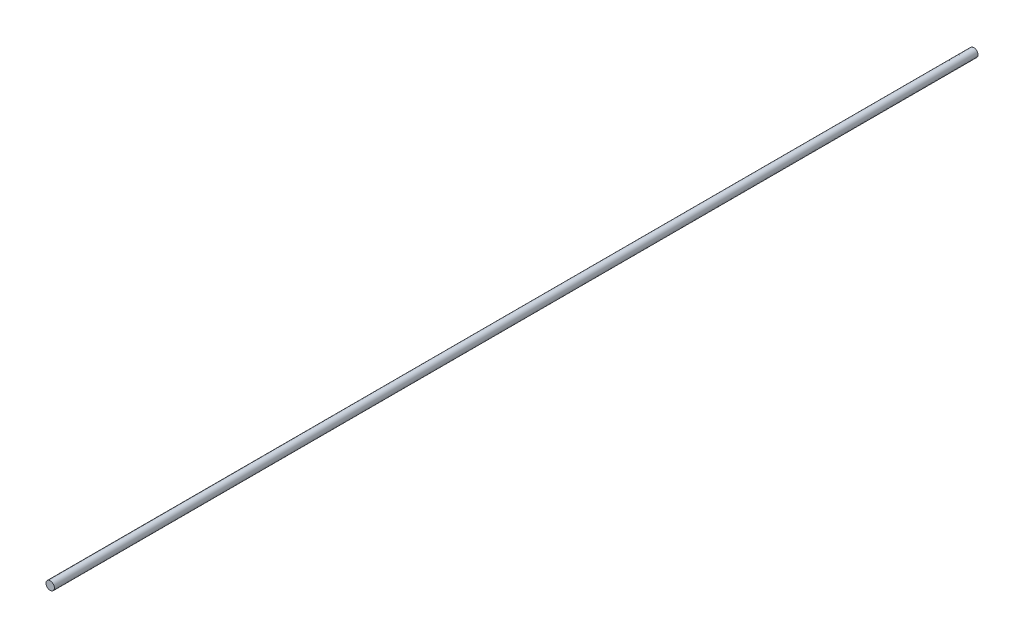
from build123d import *

# Parameters (mm, degrees)
SKETCH_1_R      = 0.5
EXTRUDE_1_DEPTH = 110


with BuildPart() as part:
    # 草图1 → 凸台-拉伸1 (new body)
    with BuildSketch(Plane.XY):
        Circle(SKETCH_1_R)
    extrude(amount=EXTRUDE_1_DEPTH)


solid = part.part
